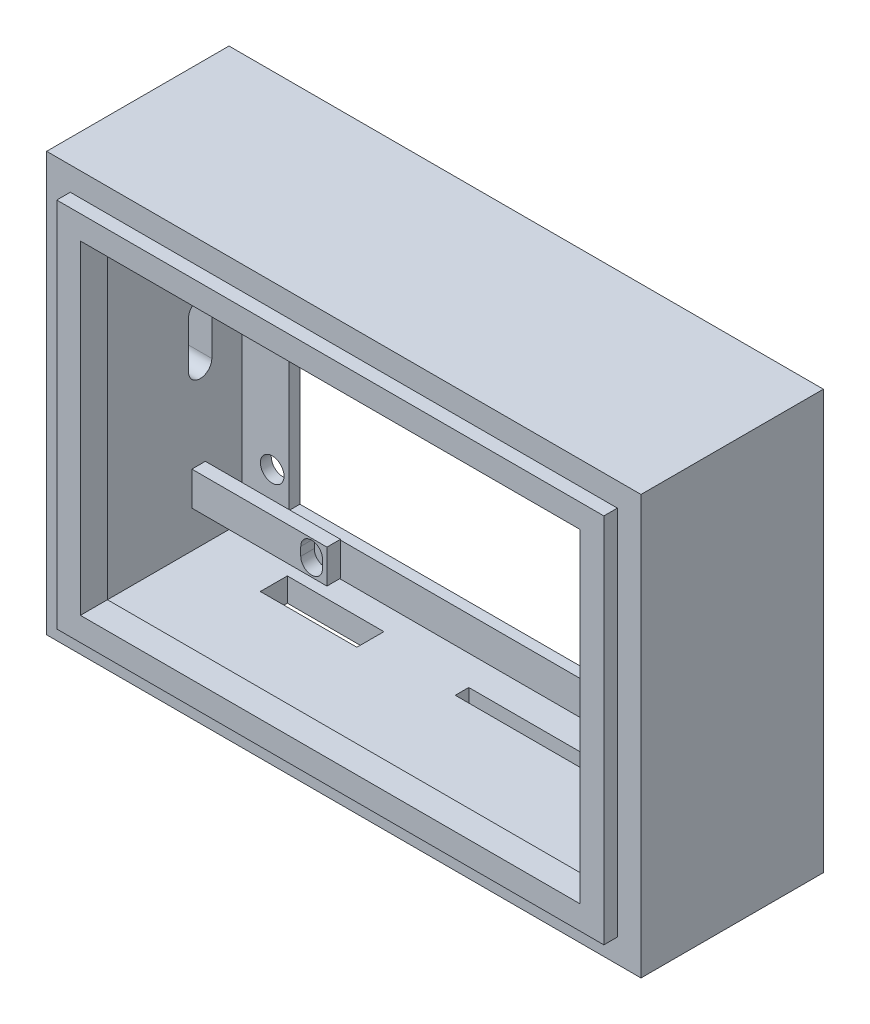
from build123d import *

# Parameters (mm, degrees)
SKETCH_1_W          = 88
SKETCH_1_H          = 62
EXTRUDE_1_DEPTH     = 2
SKETCH_2_W          = 81
SKETCH_2_H          = 55
SKETCH_2_W_2        = 74
SKETCH_2_H_2        = 48
EXTRUDE_2_DEPTH     = 2
SKETCH_3_W          = 88
SKETCH_3_H          = 62
SKETCH_3_W_2        = 81
SKETCH_3_H_2        = 55
EXTRUDE_3_DEPTH     = 25
SKETCH_5_W          = 74
SKETCH_5_H          = 48
CUT_EXTRUDE_1_DEPTH = 20
SKETCH_6_W          = 7
SKETCH_6_H          = 45
SKETCH_6_R          = 1.75
SKETCH_6_W_2        = 2
EXTRUDE_4_DEPTH     = 1.6
SKETCH_8_W          = 2
SKETCH_8_H          = 5
EXTRUDE_5_DEPTH     = 20
CUT_EXTRUDE_2_DEPTH = 17
SKETCH_7_W          = 34
SKETCH_7_H          = 2
SKETCH_7_W_2        = 14.295678294
SKETCH_7_H_2        = 4
CUT_EXTRUDE_3_DEPTH = 5
CUT_EXTRUDE_4_DEPTH = 5


with BuildPart() as part:
    # 草图1 → 凸台-拉伸1 (new body)
    with BuildSketch(Plane.XY):
        with Locations((44, -31)):
            Rectangle(SKETCH_1_W, SKETCH_1_H)
    extrude(amount=EXTRUDE_1_DEPTH)

    # 草图2 → 凸台-拉伸2 (add)
    with BuildSketch(Plane.XY.offset(2)):
        with Locations((44, -31)):
            Rectangle(SKETCH_2_W, SKETCH_2_H)
        with Locations((44, -31)):
            Rectangle(SKETCH_2_W_2, SKETCH_2_H_2, mode=Mode.SUBTRACT)
    extrude(amount=EXTRUDE_2_DEPTH)

    # 草图3 → 凸台-拉伸3 (add)
    with BuildSketch(Plane(origin=(0, 0, 0), x_dir=(-1, 0, 0), z_dir=(0, 0, -1))):
        with Locations((-44, -31)):
            Rectangle(SKETCH_3_W, SKETCH_3_H)
        with Locations((-44, -31)):
            Rectangle(SKETCH_3_W_2, SKETCH_3_H_2, mode=Mode.SUBTRACT)
    extrude(amount=EXTRUDE_3_DEPTH)

    # 草图5 → 切除-拉伸1 (cut)
    with BuildSketch(Plane.XY.offset(2)):
        with Locations((44, -31)):
            Rectangle(SKETCH_5_W, SKETCH_5_H)
    extrude(amount=-CUT_EXTRUDE_1_DEPTH, mode=Mode.SUBTRACT)

    # 草图6 → 凸台-拉伸4 (add)
    with BuildSketch(Plane(origin=(0, 0, -25), x_dir=(-1, 0, 0), z_dir=(0, 0, -1))):
        Polygon((-3.5, -3.5), (-84.5, -3.5), (-84.5, -8.5), (-82.5, -8.5), (-10.5, -8.5), (-3.5, -8.5), align=None)
        with Locations((-7, -31)):
            Rectangle(SKETCH_6_W, SKETCH_6_H)
        with Locations((-8, -49.5)):
            Circle(SKETCH_6_R, mode=Mode.SUBTRACT)
        with Locations((-8, -12.5)):
            Circle(SKETCH_6_R, mode=Mode.SUBTRACT)
        with Locations((-83.5, -31)):
            Rectangle(SKETCH_6_W_2, SKETCH_6_H)
        Polygon((-82.5, -53.5), (-84.5, -53.5), (-84.5, -58.5), (-3.5, -58.5), (-3.5, -53.5), (-10.5, -53.5), align=None)
    extrude(amount=-EXTRUDE_4_DEPTH)

    # 草图8 → 凸台-拉伸5 (add)
    with BuildSketch(Plane(origin=(3.5, 0, 0), x_dir=(0, 0, -1), z_dir=(1, 0, 0))):
        with Locations((17, -50.5)):
            Rectangle(SKETCH_8_W, SKETCH_8_H)
    extrude(amount=EXTRUDE_5_DEPTH)

    # 草图10 → 切除-拉伸2 (cut)
    with BuildSketch(Plane(origin=(0, 0, -18), x_dir=(-1, 0, 0), z_dir=(0, 0, -1))):
        with BuildLine():
            Line((-19.62339277, -49.845001647), (-19.62339277, -51.119762416))
            ThreePointArc((-19.62339277, -51.119762416), (-21.228647072, -52.725016718), (-22.833901374, -51.119762416))
            Line((-22.833901374, -51.119762416), (-22.833901374, -49.845001647))
            ThreePointArc((-22.833901374, -49.845001647), (-21.228647072, -48.239747346), (-19.62339277, -49.845001647))
        make_face()
    extrude(amount=-CUT_EXTRUDE_2_DEPTH, mode=Mode.SUBTRACT)

    # 草图7 → 切除-拉伸3 (cut)
    with BuildSketch(Plane.XZ.offset(62)):
        with Locations((58.5, -18)):
            Rectangle(SKETCH_7_W, SKETCH_7_H)
        with Locations((20.909824804, -17.875130222)):
            Rectangle(SKETCH_7_W_2, SKETCH_7_H_2)
    extrude(amount=-CUT_EXTRUDE_3_DEPTH, mode=Mode.SUBTRACT)

    # 草图11 → 切除-拉伸4 (cut)
    with BuildSketch(Plane.ZY):
        with BuildLine():
            Line((-15.507327091, -28.393704354), (-15.507327091, -35.287349512))
            ThreePointArc((-15.507327091, -35.287349512), (-17.230738381, -37.010760802), (-18.954149671, -35.287349512))
            Line((-18.954149671, -35.287349512), (-18.954149671, -28.393704354))
            ThreePointArc((-18.954149671, -28.393704354), (-17.230738381, -26.670293064), (-15.507327091, -28.393704354))
        make_face()
    extrude(amount=-CUT_EXTRUDE_4_DEPTH, mode=Mode.SUBTRACT)


solid = part.part
